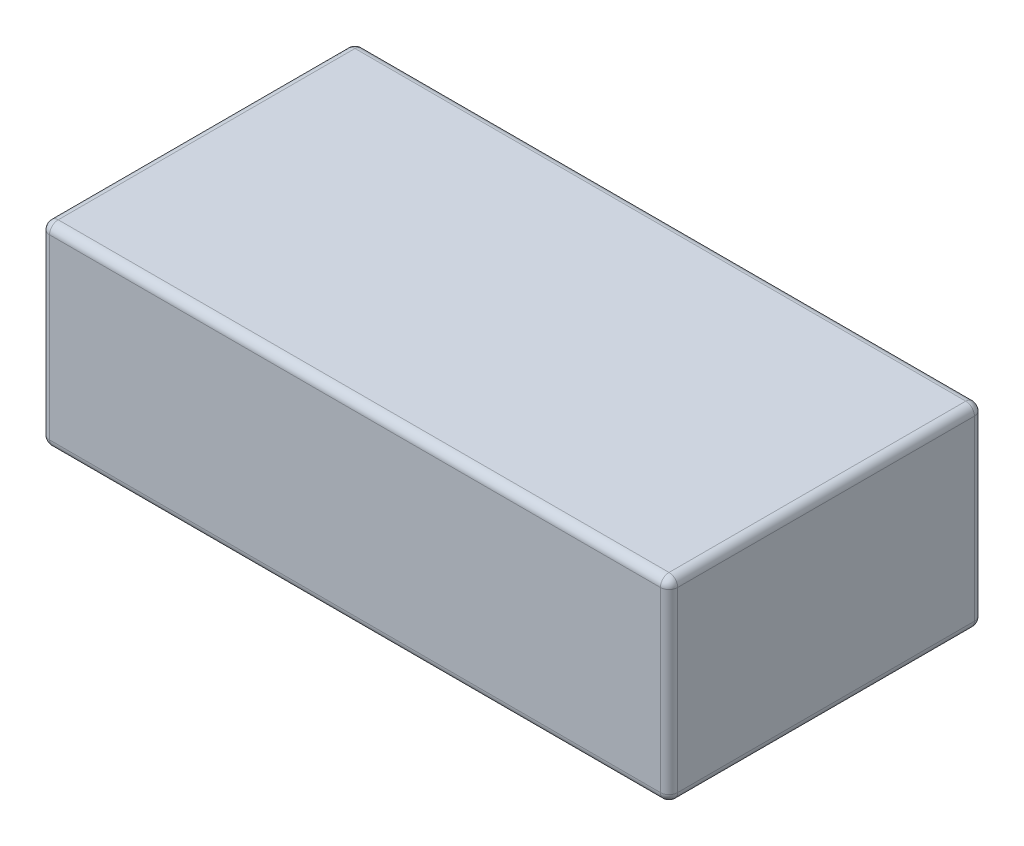
from build123d import *

# Parameters (mm, degrees)
SKETCH1_W           = 184.15
SKETCH1_H           = 92.075
BOSS_EXTRUDE1_DEPTH = 57.15
FILLET1_R           = 2.54


with BuildPart() as part:
    # Sketch1 → Boss-Extrude1 (new body)
    with BuildSketch(Plane(origin=(0, 0, 0), x_dir=(1, 0, 0), z_dir=(0, 1, 0))):
        Rectangle(SKETCH1_W, SKETCH1_H)
    extrude(amount=BOSS_EXTRUDE1_DEPTH)

    # Fillet1
    fillet1_edges = [part.edges().sort_by_distance(p)[0] for p in [
        (-92.075, 57.15, 0),
        (0, 57.15, 46.0375),
        (92.075, 57.15, 0),
        (0, 0, 46.0375),
        (-92.075, 0, 0),
        (0, 0, -46.0375),
        (92.075, 0, 0),
        (0, 57.15, -46.0375),
        (92.075, 28.575, 46.0375),
        (-92.075, 28.575, 46.0375),
        (-92.075, 28.575, -46.0375),
        (92.075, 28.575, -46.0375),
    ]]
    fillet(fillet1_edges, radius=FILLET1_R)


solid = part.part
